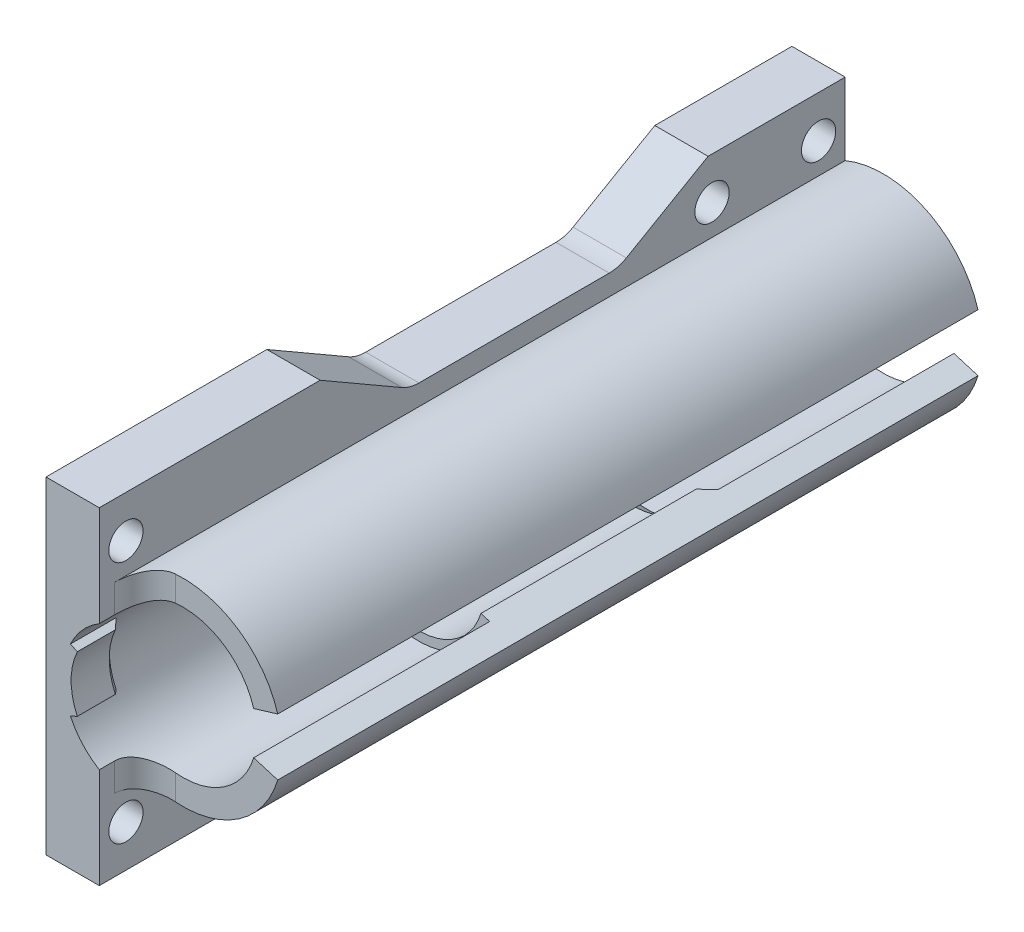
from build123d import *

# Parameters (mm, degrees)
BOSS_EXTRUDE1_DEPTH      = 98
SKETCH2_R                = 2.25
CUT_EXTRUDE1_DEPTH       = 25.44661253
SKETCH4_W                = 19.691623847
SKETCH4_H                = 43
CUT_EXTRUDE2_DEPTH       = 6
FILLET1_R                = 4
CUT_EXTRUDE3_DEPTH       = 62.0000001
CUT_EXTRUDE4_DEPTH       = 25.44661263
REVOLVE2_ANGLE           = 25
REVOLVE2_OTHER_WAY_ANGLE = 25


with BuildPart() as part:
    # Sketch1 → Boss-Extrude1 (new body)
    with BuildSketch(Plane.XY):
        with BuildLine():
            Line((-5, -12), (-5, -21.5))
            Line((-5, -21.5), (-12, -21.5))
            Line((-12, -21.5), (-12, 21.5))
            Line((-12, 21.5), (-5, 21.5))
            Line((-5, 21.5), (-5, 12))
            ThreePointArc((-5, 12), (5.555898195, 11.752956872), (12.44661253, 3.75257732))
            Line((12.44661253, 3.75257732), (9.287087811, 2.8))
            ThreePointArc((9.287087811, 2.8), (-9.7, 0), (9.287087811, -2.8))
            Line((9.287087811, -2.8), (12.44661253, -3.75257732))
            ThreePointArc((12.44661253, -3.75257732), (5.555898195, -11.752956872), (-5, -12))
        make_face()
    extrude(amount=BOSS_EXTRUDE1_DEPTH)

    # Sketch2 → Cut-Extrude1 (cut, through all)
    with BuildSketch(Plane.ZY.offset(12)):
        with Locations((3.5, 16)):
            Circle(SKETCH2_R)
        with Locations((94.5, -16)):
            Circle(SKETCH2_R)
        with Locations((94.5, 16)):
            Circle(SKETCH2_R)
        with Locations((3.5, -16)):
            Circle(SKETCH2_R)
        with Locations((17.5, 16)):
            Circle(SKETCH2_R)
        with Locations((17.5, -16)):
            Circle(SKETCH2_R)
    extrude(amount=-CUT_EXTRUDE1_DEPTH, mode=Mode.SUBTRACT)

    # Sketch3 → Revolve1 (revolve)
    with BuildSketch(Plane.ZY, mode=Mode.PRIVATE) as revolve1_sk:
        Polygon((31, 9.7), (32.713777608, 8.5), (61, 8.5), (61, 9.7), align=None)
    revolve(revolve1_sk.sketch.rotate(Axis((0, 0, 0), (0, 0, 1)), 90), axis=Axis((0, 0, 0), (0, 0, 1)))  # turned: the seam where the file's is

    # Sketch4 → Cut-Extrude2 (cut)
    with BuildSketch(Plane.XY.offset(98)):
        with Locations((4.845811924, 0)):
            Rectangle(SKETCH4_W, SKETCH4_H)
    extrude(amount=-CUT_EXTRUDE2_DEPTH, mode=Mode.SUBTRACT)

    # Fillet1
    fillet1_edges = [part.edges().sort_by_distance(p)[0] for p in [
        (-5, 10.15601973, 92),
        (-5, -10.15601973, 92),
    ]]
    fillet(fillet1_edges, radius=FILLET1_R)

    # Sketch5 → Cut-Extrude3 (cut, through all)
    with BuildSketch(Plane.XY.offset(61)):
        with BuildLine():
            Line((8.138169731, 2.453608247), (9.287087811, 2.8))
            ThreePointArc((9.287087811, 2.8), (9.7, 0), (9.287087811, -2.8))
            Line((9.287087811, -2.8), (8.138169731, -2.453608247))
            ThreePointArc((8.138169731, -2.453608247), (8.5, 0), (8.138169731, 2.453608247))
        make_face()
    extrude(amount=-CUT_EXTRUDE3_DEPTH, mode=Mode.SUBTRACT)

    # Sketch6 → Cut-Extrude4 (cut, through all)
    with BuildSketch(Plane.ZY.offset(12)):
        with BuildLine():
            Line((28.75, 15.302885683), (18.016283143, 21.5))
            Line((18.016283143, 21.5), (68.983716857, 21.5))
            Line((68.983716857, 21.5), (58.25, 15.302885683))
            ThreePointArc((58.25, 15.302885683), (57.164685703, 14.853333782), (56, 14.7))
            Line((56, 14.7), (31, 14.7))
            ThreePointArc((31, 14.7), (29.835314297, 14.853333782), (28.75, 15.302885683))
        make_face()
    cut_extrude4 = extrude(amount=-CUT_EXTRUDE4_DEPTH, mode=Mode.SUBTRACT)

    # Mirror1: Cut-Extrude4 across plane
    add(cut_extrude4.mirror(Plane.ZX), mode=Mode.SUBTRACT)

    # Sketch7 → Revolve2 (revolve)
    with BuildSketch(Plane(origin=(0, 0, 0), x_dir=(1, 0, 0), z_dir=(0, 1, 0))):
        Polygon((-9.7, -92), (-9.7, -98), (-8.7, -98), (-8.7, -93), align=None)
    revolve(axis=Axis((0, 0, 97.129634248), (0, 0, -1)), revolution_arc=REVOLVE2_ANGLE)

    # Sketch7 → Revolve2 other way (revolve)
    with BuildSketch(Plane(origin=(0, 0, 0), x_dir=(1, 0, 0), z_dir=(0, 1, 0))):
        Polygon((-9.7, -92), (-9.7, -98), (-8.7, -98), (-8.7, -93), align=None)
    revolve(axis=Axis((0, 0, 97.129634248), (0, 0, 1)), revolution_arc=REVOLVE2_OTHER_WAY_ANGLE)


solid = part.part
